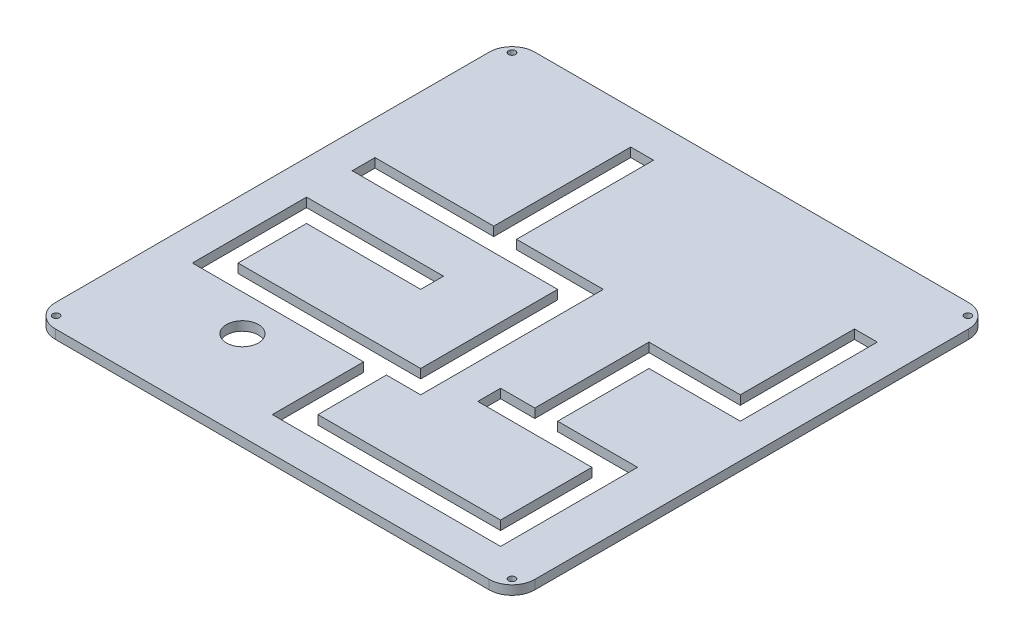
from build123d import *

# Parameters (mm, degrees)
SKETCH1_W         = 210
SKETCH1_H         = 210
MAINEXTRUDE_DEPTH = 4
SKETCH1_6_R       = 1.5
SCREWHOLES_DEPTH  = 4
ROUNDEDCORNERS_R  = 10
SKETCH3_R         = 7
TRENCH_DEPTH      = 4


with BuildPart() as part:
    # Sketch1 → MainExtrude (new body)
    with BuildSketch(Plane(origin=(0, 0, 0), x_dir=(1, 0, 0), z_dir=(0, 1, 0))):
        Rectangle(SKETCH1_W, SKETCH1_H)
    extrude(amount=MAINEXTRUDE_DEPTH)

    # Sketch1_6 → ScrewHoles (cut)
    with BuildSketch(Plane(origin=(0, 0, 0), x_dir=(1, 0, 0), z_dir=(0, 1, 0))):
        with Locations((-99.833273811, 99.833273811)):
            Circle(SKETCH1_6_R)
        with Locations((-99.833273811, -99.833273811)):
            Circle(SKETCH1_6_R)
        with Locations((99.833273811, -99.833273811)):
            Circle(SKETCH1_6_R)
        with Locations((99.833273811, 99.833273811)):
            Circle(SKETCH1_6_R)
    extrude(amount=SCREWHOLES_DEPTH, mode=Mode.SUBTRACT)

    # RoundedCorners
    roundedcorners_edges = [part.edges().sort_by_distance(p)[0] for p in [
        (-105, 2, -105),
        (-105, 2, 105),
        (105, 2, 105),
        (105, 2, -105),
    ]]
    fillet(roundedcorners_edges, radius=ROUNDEDCORNERS_R)

    # Sketch3 → Trench (cut)
    with BuildSketch(Plane(origin=(0, 0, 0), x_dir=(1, 0, 0), z_dir=(0, 1, 0))):
        with Locations((-52.205723714, -65.868416485)):
            Circle(SKETCH3_R)
        Polygon((-38, 90), (-38, 30), (-90, 30), (-90, 20), (0, 20), (0, -40), (-80, -40), (-80, -10), (-30, -10), (-30, 0), (-90, 0), (-90, -50), (-15, -50), (-15, -90), (85, -90), (85, -30), (50, -30), (50, 10), (90, 10), (90, 70), (80, 70), (80, 20), (40, 20), (40, -30), (25, -30), (25, -40), (75, -40), (75, -80), (-5, -80), (-5, -50), (10, -50), (10, 30), (-28, 30), (-28, 90), align=None)
    extrude(amount=TRENCH_DEPTH, mode=Mode.SUBTRACT)


solid = part.part
